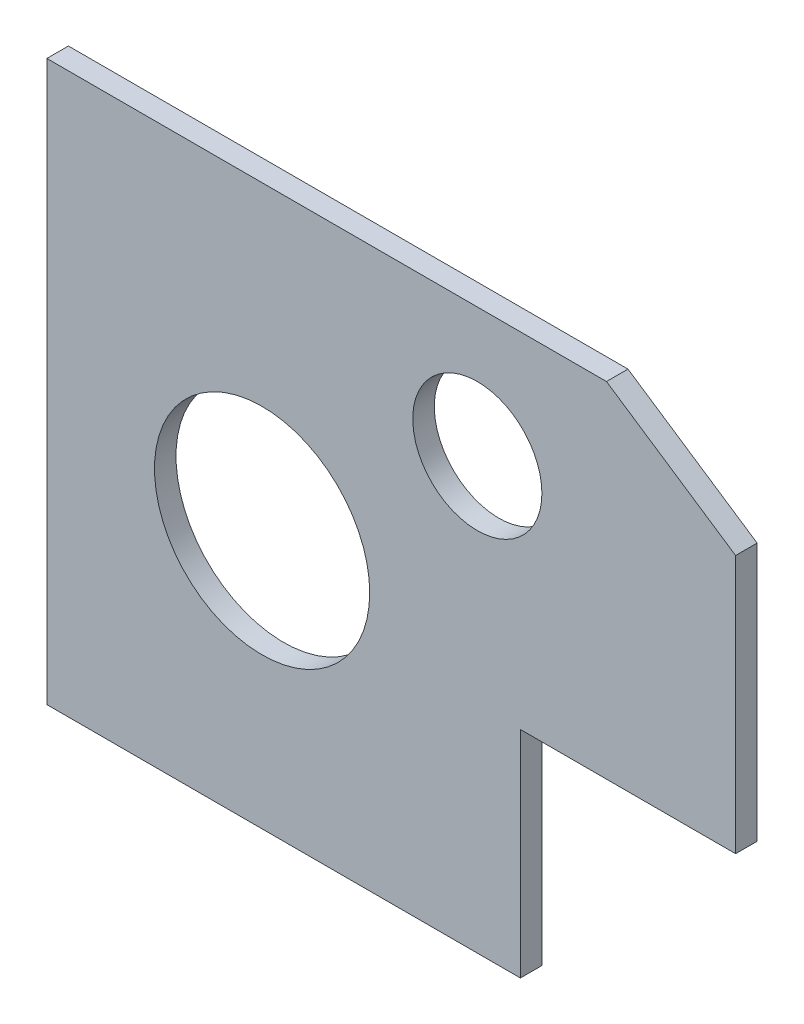
from build123d import *

# Parameters (mm, degrees)
SKETCH2_R           = 31.75
SKETCH2_R_2         = 19.05
BOSS_EXTRUDE1_DEPTH = 6.35


with BuildPart() as part:
    # Sketch2 → Boss-Extrude1 (new body)
    with BuildSketch(Plane.XY):
        Polygon((0, 0), (0, 165.1), (165.1, 165.1), (203.2, 139.7), (203.2, 63.5), (139.7, 63.5), (139.7, 0), align=None)
        with Locations((63.5, 76.2)):
            Circle(SKETCH2_R, mode=Mode.SUBTRACT)
        with Locations((127, 127)):
            Circle(SKETCH2_R_2, mode=Mode.SUBTRACT)
    extrude(amount=BOSS_EXTRUDE1_DEPTH)


solid = part.part
